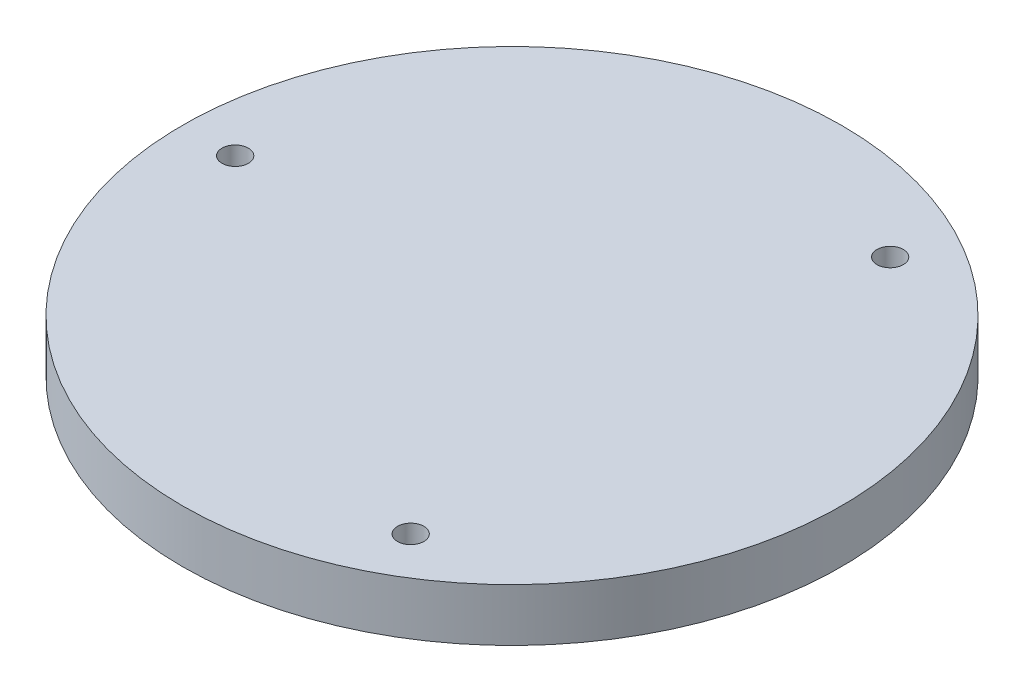
from build123d import *

# Parameters (mm, degrees)
SKETCH1_R                                           = 125
PLATE_DEPTH                                         = 20
CBORE_FOR_M5_HEX_SOCKET_HEAD_CAP_SCREW1_D           = 5.3
CBORE_FOR_M5_HEX_SOCKET_HEAD_CAP_SCREW1_CBORE_D     = 10
CBORE_FOR_M5_HEX_SOCKET_HEAD_CAP_SCREW1_CBORE_DEPTH = 15.4
CIRPATTERN1_COUNT                                   = 3


with BuildPart() as part:
    # Sketch1 → Plate (new body)
    with BuildSketch(Plane(origin=(0, 0, 0), x_dir=(1, 0, 0), z_dir=(0, 1, 0))):
        Circle(SKETCH1_R)
    extrude(amount=PLATE_DEPTH)

    # CBORE for M5 Hex Socket Head Cap Screw1 (through all)
    with Locations(Plane(origin=(0, 20, 0), x_dir=(1, 0, 0), z_dir=(0, 1, 0))):
        with Locations((-105, 0)):
            cbore_for_m5_hex_socket_head_cap_screw1 = CounterBoreHole(CBORE_FOR_M5_HEX_SOCKET_HEAD_CAP_SCREW1_D / 2, CBORE_FOR_M5_HEX_SOCKET_HEAD_CAP_SCREW1_CBORE_D / 2, CBORE_FOR_M5_HEX_SOCKET_HEAD_CAP_SCREW1_CBORE_DEPTH)

    # CirPattern1: CBORE for M5 Hex Socket Head Cap Screw1 ×3 about axis
    cirpattern1_axis = Axis((0, 0, 0), (0, 1, 0))
    for i in range(1, CIRPATTERN1_COUNT):
        add(cbore_for_m5_hex_socket_head_cap_screw1.rotate(cirpattern1_axis, i * 360 / CIRPATTERN1_COUNT), mode=Mode.SUBTRACT)


solid = part.part
